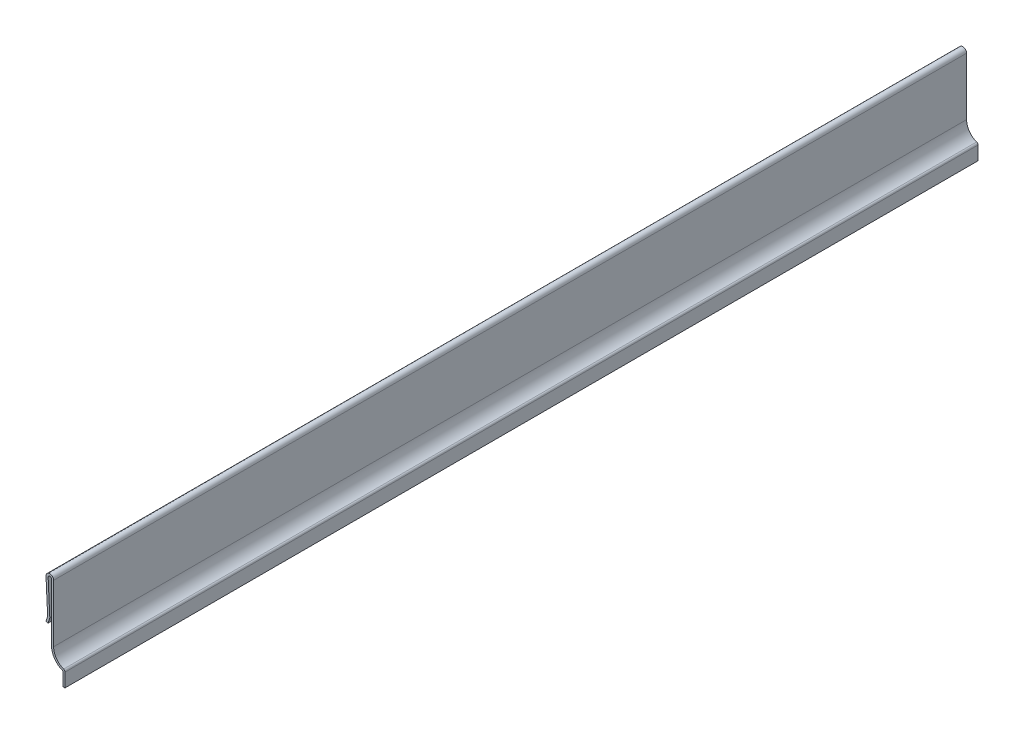
from build123d import *

# Parameters (mm, degrees)
BOSS_EXTRUDE1_DEPTH = 381
FILLET1_R           = 0.889


with BuildPart() as part:
    # Sketch1 → Boss-Extrude1 (new body)
    with BuildSketch(Plane.XY):
        with BuildLine():
            Line((0, 0), (0, 6.35))
            ThreePointArc((0, 6.35), (-3.432615786, 8.609796095), (-4.7625, 12.498361062))
            Line((-4.7625, 12.498361062), (-4.7625, 36.5125))
            ThreePointArc((-4.7625, 36.5125), (-6.388490208, 38.099533318), (-7.935633548, 36.435542215))
            Line((-7.935633548, 36.435542215), (-7.2459333, 22.225))
            Line((-7.2459333, 22.225), (-7.9375, 20.121392457))
            Line((-7.9375, 20.121392457), (-7.092967191, 19.84375))
            Line((-7.092967191, 19.84375), (-6.401400491, 21.947357543))
            ThreePointArc((-6.401400491, 21.947357543), (-6.364969814, 22.105734183), (-6.357978513, 22.26809636))
            Line((-6.357978513, 22.26809636), (-7.047678761, 36.478638575))
            ThreePointArc((-7.047678761, 36.478638575), (-6.366935691, 37.21079466), (-5.6515, 36.5125))
            Line((-5.6515, 36.5125), (-5.6515, 12.498361062))
            ThreePointArc((-5.6515, 12.498361062), (-4.342529701, 8.346509818), (-0.889, 5.696150484))
            Line((-0.889, 5.696150484), (-0.889, 0))
            Line((-0.889, 0), (0, 0))
        make_face()
    extrude(amount=-BOSS_EXTRUDE1_DEPTH)

    # Fillet1
    fillet1_edges = [part.edges().sort_by_distance(p)[0] for p in [
        (0, 6.35, -190.5),
    ]]
    fillet(fillet1_edges, radius=FILLET1_R)


solid = part.part
